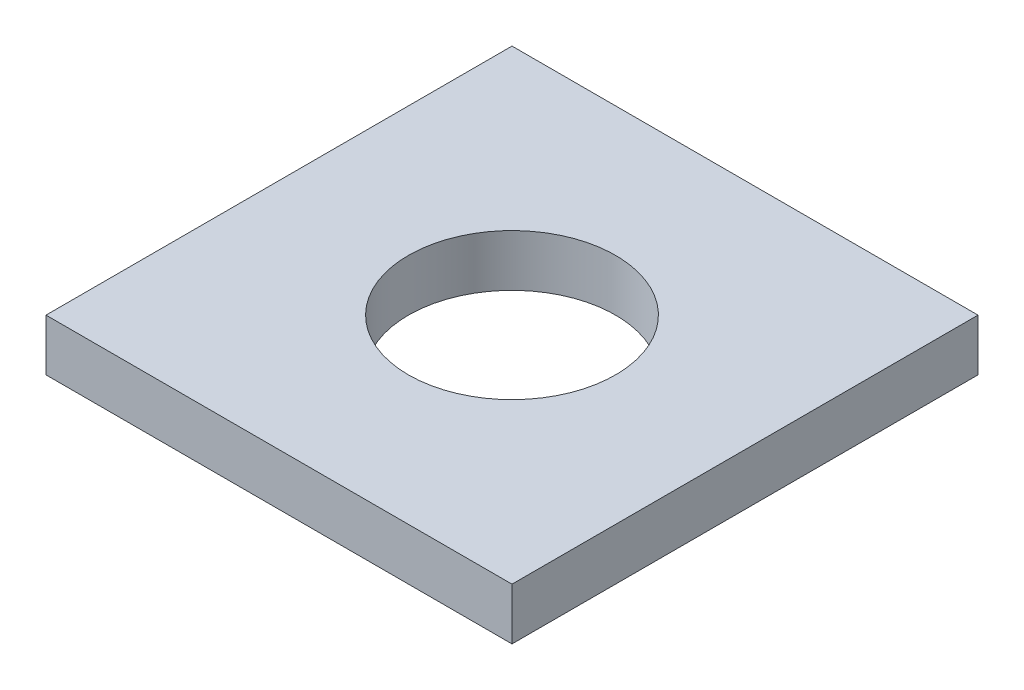
from build123d import *

# Parameters (mm, degrees)
SKETCH1_W           = 45
SKETCH1_H           = 45
SKETCH1_R           = 10
BOSS_EXTRUDE1_DEPTH = 5


with BuildPart() as part:
    # Sketch1 → Boss-Extrude1 (new body)
    with BuildSketch(Plane(origin=(0, 0, 0), x_dir=(1, 0, 0), z_dir=(0, 1, 0))):
        Rectangle(SKETCH1_W, SKETCH1_H)
        Circle(SKETCH1_R, mode=Mode.SUBTRACT)
    extrude(amount=BOSS_EXTRUDE1_DEPTH)


solid = part.part
